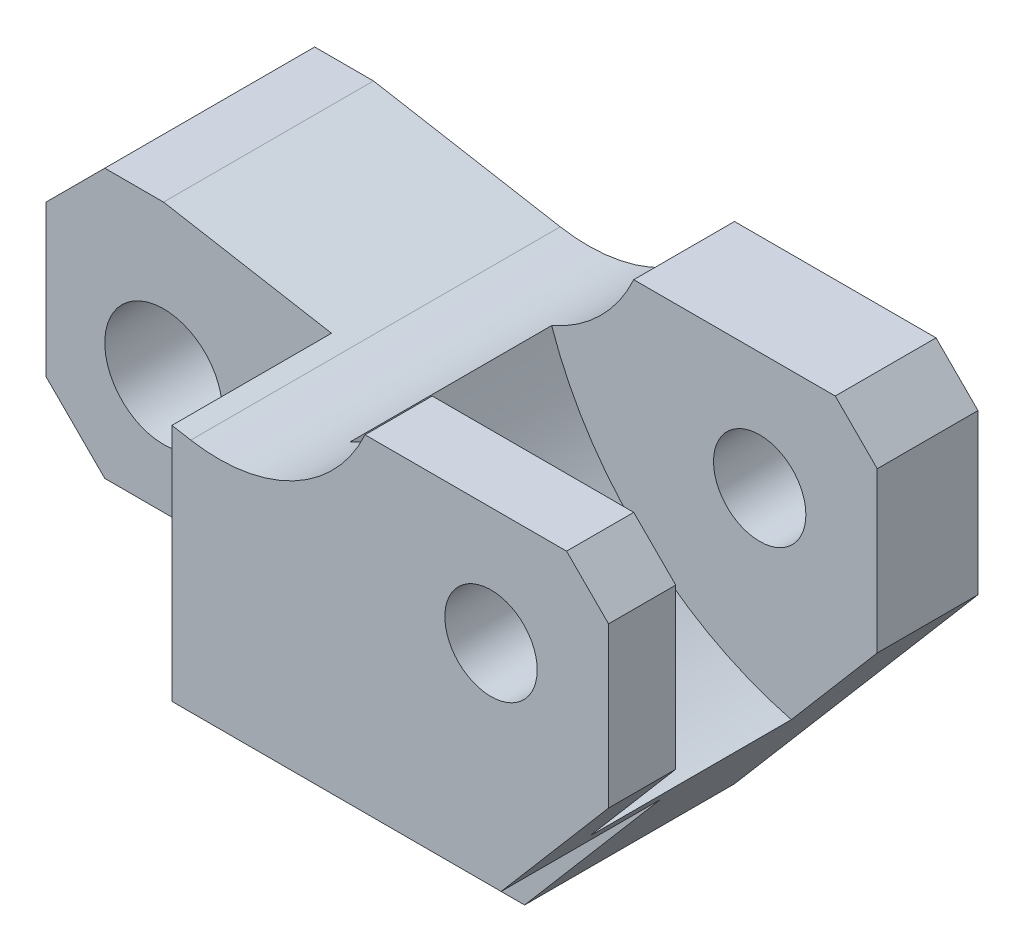
from build123d import *

# Parameters (mm, degrees)
ESQUISSE2_R             = 7
BOSS_EXTRU_2_DEPTH      = 22
ENL_V_MAT_EXTRU_1_DEPTH = 19
ESQUISSE5_R             = 5.5
ENL_V_MAT_EXTRU_2_DEPTH = 45
ENL_V_START             = -12
ENL_V_MAT_EXTRU_3_DEPTH = 24


with BuildPart() as part:
    # Esquisse2 → Boss.-Extru.2 (new body, symmetric)
    with BuildSketch(Plane.XY):
        with BuildLine():
            Line((51.296980053, -19), (57, -19))
            Line((57, -19), (86, 15))
            Line((86, 15), (86, 34))
            Line((86, 34), (81, 39))
            Line((81, 39), (57, 39))
            ThreePointArc((57, 39), (48.490791592, 29.99016727), (36.246410316, 28.077357637))
            Line((36.246410316, 28.077357637), (14, 32))
            Line((14, 32), (7, 32))
            Line((7, 32), (0, 25))
            Line((0, 25), (0, 7))
            Line((0, 7), (7, 0))
            Line((7, 0), (39.575538911, 0))
            ThreePointArc((39.575538911, 0), (42.840774692, -1.213413768), (44.521177653, -4.264705882))
            ThreePointArc((44.521177653, -4.264705882), (46.858007856, -12.115672061), (51.296980053, -19))
        make_face()
        with Locations((14, 14)):
            Circle(ESQUISSE2_R, mode=Mode.SUBTRACT)
    extrude(amount=BOSS_EXTRU_2_DEPTH, both=True)

    # Esquisse4 → Enlèv. mat.-Extru.1 (cut)
    with BuildSketch(Plane.XY.offset(22)):
        Polygon((34, 32), (0, 32), (0, -19), (86, -19), (86, 0), (34, 0), align=None)
    extrude(amount=-ENL_V_MAT_EXTRU_1_DEPTH, mode=Mode.SUBTRACT)

    # Esquisse5 → Enlèv. mat.-Extru.2 (cut, through all)
    with BuildSketch(Plane.XY.offset(22)):
        with Locations((72, 25)):
            Circle(ESQUISSE5_R)
    extrude(amount=-ENL_V_MAT_EXTRU_2_DEPTH, mode=Mode.SUBTRACT)

    # Esquisse14 → Enlèv. mat.-Extru.3 (cut)
    with BuildSketch(Plane(origin=(0, 0, -22), x_dir=(-1, 0, 0), z_dir=(0, 0, -1)).offset(ENL_V_START)):
        with BuildLine():
            Line((-75.764705882, 3), (-86, 15))
            Line((-86, 15), (-86, 34))
            Line((-86, 34), (-81, 39))
            Line((-81, 39), (-57, 39))
            ThreePointArc((-57, 39), (-53.002548038, 33.285750119), (-47.224051208, 29.381745985))
            ThreePointArc((-47.224051208, 29.381745985), (-58.169717695, 12.59414375), (-75.764705882, 3))
        make_face()
    extrude(amount=-ENL_V_MAT_EXTRU_3_DEPTH, mode=Mode.SUBTRACT)


solid = part.part
